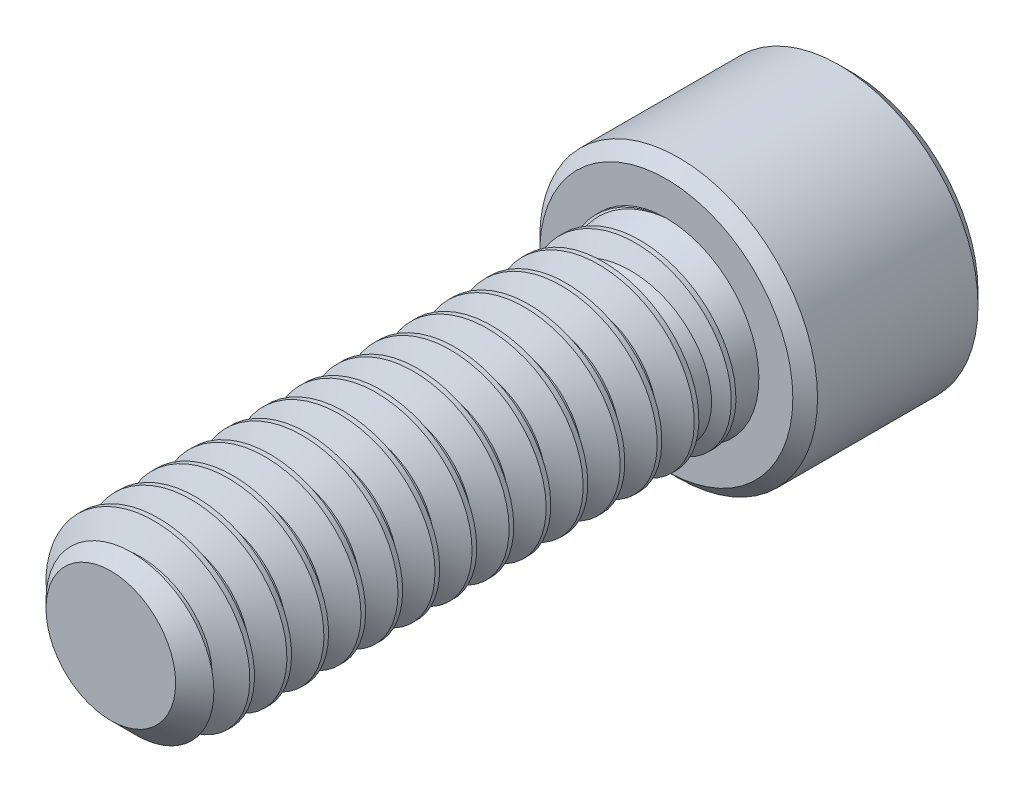
from build123d import *

# Parameters (mm, degrees)
CUT_EXTRUDE1_DEPTH     = 3.571875
CUT_SWEEP1_PITCH       = 1.27
CUT_SWEEP1_HEIGHT      = 20.32
CUT_SWEEP1_RADIUS      = 3.175
CUT_SWEEP1_START_ANGLE = 90
SKETCH7_R              = 3.175
BOSS_EXTRUDE1_DEPTH    = 19.05
BOSS_EXTRUDE1_TAPER    = 20


with BuildPart() as part:
    # Sketch2 → Revolve1 (revolve)
    with BuildSketch(Plane(origin=(0, 0, 0), x_dir=(0, 0, -1), z_dir=(1, 0, 0)), mode=Mode.PRIVATE) as revolve1_sk:
        Polygon((12.7, 0), (12.7, 4.339166667), (12.276666667, 4.7625), (6.773333333, 4.7625), (6.35, 4.339166667), (6.35, 3.175), (-11.7475, 3.175), (-12.7, 2.2225), (-12.7, 0), align=None)
    revolve(revolve1_sk.sketch.rotate(Axis((0, 0, 12.7), (0, 0, -1)), 90), axis=Axis((0, 0, 12.7), (0, 0, -1)))

    # Sketch3 → Cut-Extrude1 (cut)
    with BuildSketch(Plane(origin=(0, 0, -12.7), x_dir=(-1, 0, 0), z_dir=(0, 0, -1))):
        Polygon((0, 2.749630657), (-2.38125, 1.374815329), (-2.38125, -1.374815329), (0, -2.749630657), (2.38125, -1.374815329), (2.38125, 1.374815329), align=None)
    extrude(amount=-CUT_EXTRUDE1_DEPTH, mode=Mode.SUBTRACT)

    # Cut-Extrude2 cone 1 section (through the dimple's axis) → Cut-Extrude2 (revolve, cut)
    with BuildSketch(Plane(origin=(0, 0, -12.7), x_dir=(0, 1, 0), z_dir=(1, 0, 0))):
        Polygon((0, 0), (2.749630657, 0), (0, 2.749630657), align=None)
    revolve(axis=Axis((0, 0, -12.7), (0, 0, 1)), mode=Mode.SUBTRACT)


with BuildPart() as body_2:
    # Split1: the piece on the far side of the plane
    add(part.part)
    split(bisect_by=Plane.XY.offset(-6.35), keep=Keep.BOTTOM)


with BuildPart() as part_1:
    add(part.part)

    # Split1
    split(bisect_by=Plane.XY.offset(-6.35), keep=Keep.TOP)

    # Cut-Sweep1: sweep along a helix
    with BuildLine() as cut_sweep1_path:
        add(Helix(CUT_SWEEP1_PITCH, CUT_SWEEP1_HEIGHT, CUT_SWEEP1_RADIUS, center=(0, 0, 12.7), direction=(0, 0, -1), mode=Mode.PRIVATE).rotate(Axis((0, 0, 12.7), (0, 0, -1)), CUT_SWEEP1_START_ANGLE))
    # Sketch6 → Cut-Sweep1 (sweep, cut)
    with BuildSketch(Plane(origin=(0, 0, 0), x_dir=(0, 0, -1), z_dir=(1, 0, 0))):
        Polygon((-12.6603125, 3.243740766), (-13.8509375, 3.243740766), (-13.335, 2.350110803), (-13.17625, 2.350110803), align=None)
    sweep(path=cut_sweep1_path.line, is_frenet=True, mode=Mode.SUBTRACT)

    add(body_2.part)  # Boss-Extrude1 merges body 2
    # Sketch7 → Boss-Extrude1 (add)
    with BuildSketch(Plane.XY.offset(-6.35)):
        Circle(SKETCH7_R)
    extrude(amount=BOSS_EXTRUDE1_DEPTH, taper=BOSS_EXTRUDE1_TAPER)


solid = part_1.part
